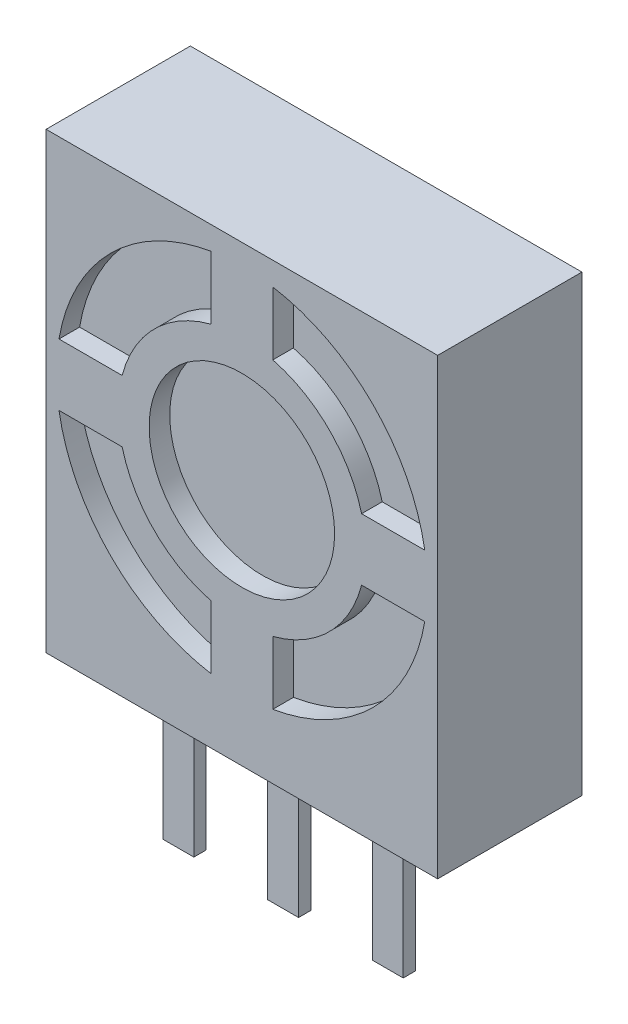
from build123d import *

# Parameters (mm, degrees)
SKETCH_1_W                 = 9.5
SKETCH_1_H                 = 11
EXTRUDE_1_DEPTH            = 3.5
SKETCH_2_R                 = 2.25
CUT_EXTRUDE_1_DEPTH        = 0.5
SKETCH_4_W                 = 0.75
SKETCH_4_H                 = 0.3
EXTRUDE_2_DEPTH            = 3.5
PATTERN_LINEAR_1_COUNT     = 2
PATTERN_LINEAR_1_PITCH     = 2.54
PATTERN_LINEAR_1_COL_COUNT = 2
PATTERN_LINEAR_1_COL_PITCH = 2.54


with BuildPart() as part:
    # 스케치1 → 보스-돌출1 (new body)
    with BuildSketch(Plane.XY):
        Rectangle(SKETCH_1_W, SKETCH_1_H)
    extrude(amount=EXTRUDE_1_DEPTH)

    # 스케치2 → 컷-돌출1 (cut)
    with BuildSketch(Plane.XY.offset(3.5)):
        with Locations((0, 0.5)):
            Circle(SKETCH_2_R)
        with BuildLine():
            Line((0.75, 4.937059837), (0.75, 3.40473751))
            ThreePointArc((0.75, 3.40473751), (2.121320344, 2.621320344), (2.90473751, 1.25))
            Line((2.90473751, 1.25), (4.437059837, 1.25))
            ThreePointArc((4.437059837, 1.25), (3.181980515, 3.681980515), (0.75, 4.937059837))
        make_face()
        with BuildLine():
            Line((-0.75, 4.937059837), (-0.75, 3.40473751))
            ThreePointArc((-0.75, 3.40473751), (-2.121320344, 2.621320344), (-2.90473751, 1.25))
            Line((-2.90473751, 1.25), (-4.437059837, 1.25))
            ThreePointArc((-4.437059837, 1.25), (-3.181980515, 3.681980515), (-0.75, 4.937059837))
        make_face()
        with BuildLine():
            Line((-4.437059837, -0.25), (-2.90473751, -0.25))
            ThreePointArc((-2.90473751, -0.25), (-2.121320344, -1.621320344), (-0.75, -2.40473751))
            Line((-0.75, -2.40473751), (-0.75, -3.937059837))
            ThreePointArc((-0.75, -3.937059837), (-3.181980515, -2.681980515), (-4.437059837, -0.25))
        make_face()
        with BuildLine():
            Line((0.75, -2.40473751), (0.75, -3.937059837))
            ThreePointArc((0.75, -3.937059837), (3.181980515, -2.681980515), (4.437059837, -0.25))
            Line((4.437059837, -0.25), (2.90473751, -0.25))
            ThreePointArc((2.90473751, -0.25), (2.121320344, -1.621320344), (0.75, -2.40473751))
        make_face()
    extrude(amount=-CUT_EXTRUDE_1_DEPTH, mode=Mode.SUBTRACT)


with BuildPart() as body_2:
    # 스케치4 → 보스-돌출2 (new body)
    with BuildSketch(Plane.XZ.offset(5.5)):
        with Locations((0, 2.35)):
            Rectangle(SKETCH_4_W, SKETCH_4_H)
    extrude_2 = extrude(amount=EXTRUDE_2_DEPTH)


with BuildPart() as pattern_linear_1_1:
    # 선형 패턴1: 보스-돌출2 ×2
    with Locations(*[(-i * PATTERN_LINEAR_1_PITCH, 0, 0) for i in range(1, PATTERN_LINEAR_1_COUNT)]):
        add(extrude_2)


with BuildPart() as pattern_linear_1_col_1:
    # 선형 패턴1 col: 보스-돌출2 ×2
    with Locations(*[(i * PATTERN_LINEAR_1_COL_PITCH, 0, 0) for i in range(1, PATTERN_LINEAR_1_COL_COUNT)]):
        add(extrude_2)


solid = Compound([part.part, body_2.part, pattern_linear_1_1.part, pattern_linear_1_col_1.part])
